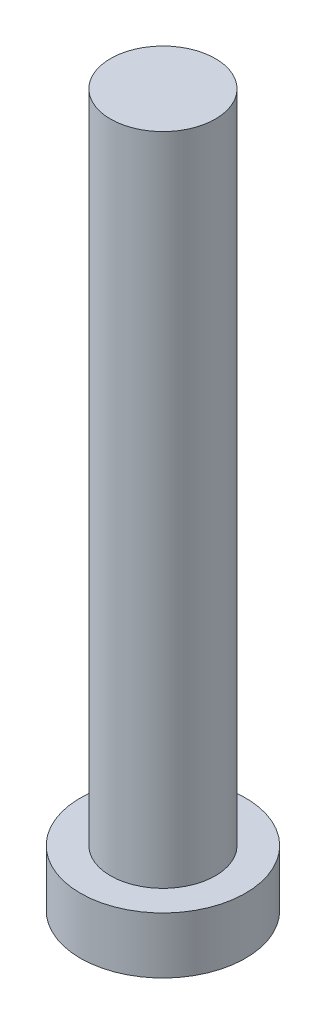
from build123d import *

# Parameters (mm, degrees)
SKETCH_1_R          = 3.15
EXTRUDE_1_DEPTH     = 2.15
SKETCH_2_R          = 2
EXTRUDE_2_DEPTH     = 25
CUT_EXTRUDE_1_DEPTH = 1.5


with BuildPart() as part:
    # 草图1 → 凸台-拉伸1 (new body)
    with BuildSketch(Plane(origin=(0, 0, 0), x_dir=(1, 0, 0), z_dir=(0, 1, 0))):
        Circle(SKETCH_1_R)
    extrude(amount=EXTRUDE_1_DEPTH)

    # 草图2 → 凸台-拉伸2 (add)
    with BuildSketch(Plane(origin=(0, 2.15, 0), x_dir=(1, 0, 0), z_dir=(0, 1, 0))):
        Circle(SKETCH_2_R)
    extrude(amount=EXTRUDE_2_DEPTH)

    # 草图3 → 切除-拉伸1 (cut)
    with BuildSketch(Plane.XZ):
        with BuildLine():
            Line((-0.5, 1), (-0.5, 2))
            Line((-0.5, 2), (0.5, 2))
            Line((0.5, 2), (0.5, 1))
            ThreePointArc((0.5, 1), (0.646446609, 0.646446609), (1, 0.5))
            Line((1, 0.5), (2, 0.5))
            Line((2, 0.5), (2, -0.5))
            Line((2, -0.5), (1, -0.5))
            ThreePointArc((1, -0.5), (0.646446609, -0.646446609), (0.5, -1))
            Line((0.5, -1), (0.5, -2))
            Line((0.5, -2), (-0.5, -2))
            Line((-0.5, -2), (-0.5, -1))
            ThreePointArc((-0.5, -1), (-0.646446609, -0.646446609), (-1, -0.5))
            Line((-1, -0.5), (-2, -0.5))
            Line((-2, -0.5), (-2, 0.5))
            Line((-2, 0.5), (-1, 0.5))
            ThreePointArc((-1, 0.5), (-0.646446609, 0.646446609), (-0.5, 1))
        make_face()
    extrude(amount=-CUT_EXTRUDE_1_DEPTH, mode=Mode.SUBTRACT)


solid = part.part
